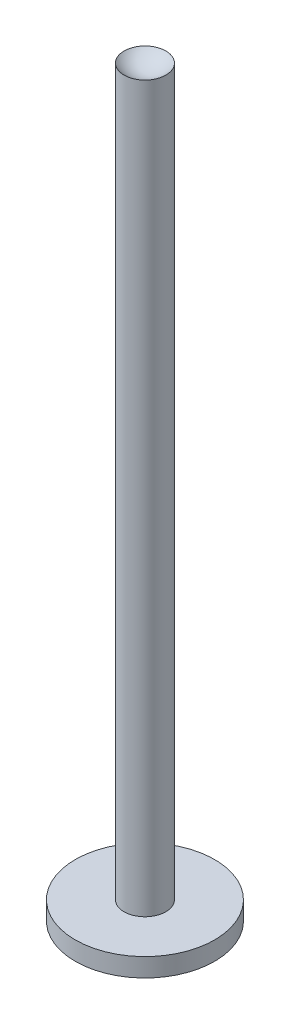
from build123d import *

# Parameters (mm, degrees)
SKETCH1_R           = 75
BOSS_EXTRUDE1_DEPTH = 20
SKETCH2_R           = 22.5
BOSS_EXTRUDE2_DEPTH = 780


with BuildPart() as part:
    # Sketch1 → Boss-Extrude1 (new body)
    with BuildSketch(Plane(origin=(0, 0, 0), x_dir=(1, 0, 0), z_dir=(0, 1, 0))):
        Circle(SKETCH1_R)
    extrude(amount=BOSS_EXTRUDE1_DEPTH)

    # Sketch2 → Boss-Extrude2 (add)
    with BuildSketch(Plane(origin=(0, 20, 0), x_dir=(1, 0, 0), z_dir=(0, 1, 0))):
        Circle(SKETCH2_R)
    extrude(amount=BOSS_EXTRUDE2_DEPTH)

    # Sketch4 → Cut-Revolve1 (revolve, cut)
    with BuildSketch(Plane(origin=(0, 0, 0), x_dir=(0, 0, -1), z_dir=(1, 0, 0))):
        with BuildLine():
            Line((0, 800), (-22.5, 800))
            ThreePointArc((-22.5, 800), (-12.311072252, 792.612587432), (0, 790))
            Line((0, 790), (0, 800))
        make_face()
    revolve(axis=Axis((0, 783.697468949, 0), (0, 1, 0)), mode=Mode.SUBTRACT)


solid = part.part
